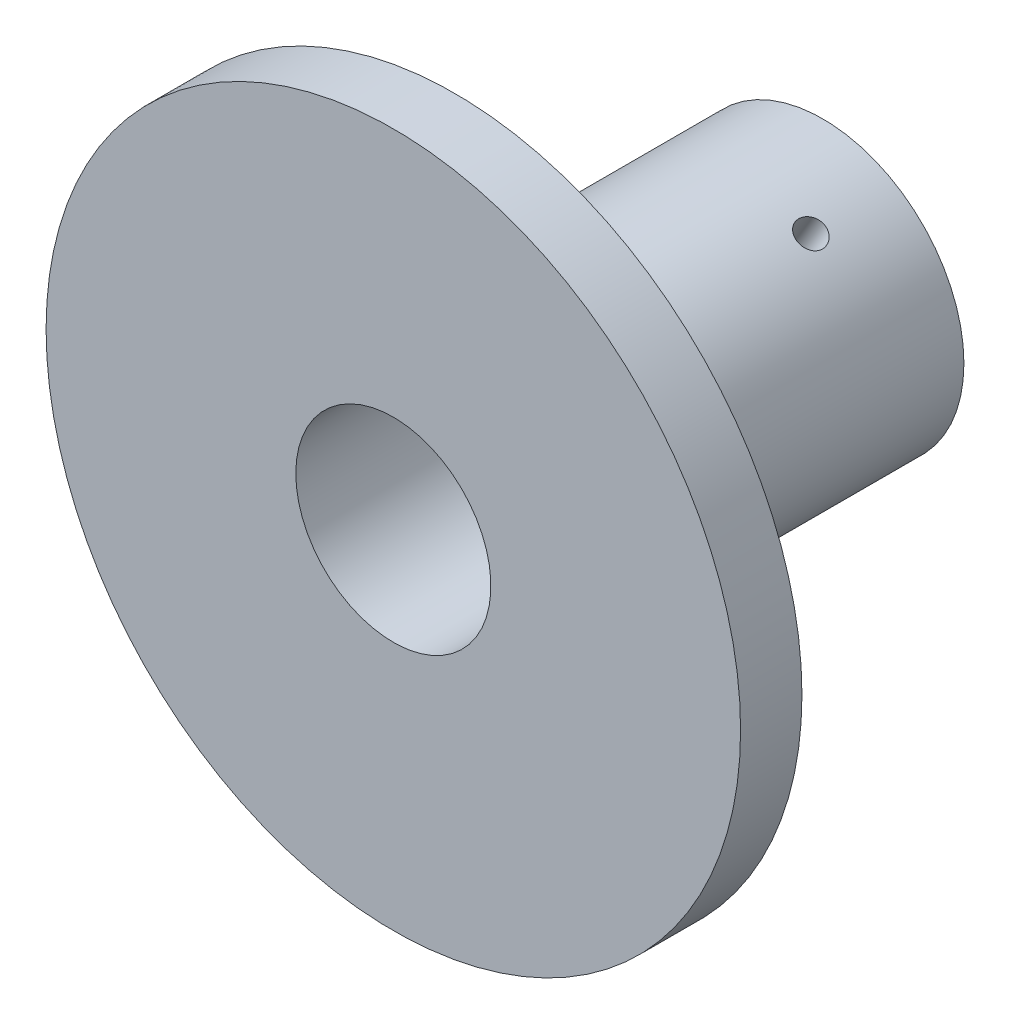
from build123d import *

# Parameters (mm, degrees)
SKETCH1_R                  = 28.3
BOSS_EXTRUDE1_DEPTH        = 5
SKETCH4_R                  = 11.5
BOSS_EXTRUDE2_DEPTH        = 30
SKETCH10_R                 = 7.95
CUT_EXTRUDE4_DEPTH         = 36
F_4_40_TAPPED_HOLE2_REACH  = 42.359
F_4_40_TAPPED_HOLE2_BORE_R = 1.1303
CIRPATTERN3_COUNT          = 3


with BuildPart() as part:
    # Sketch1 → Boss-Extrude1 (new body)
    with BuildSketch(Plane.XY):
        Circle(SKETCH1_R)
    extrude(amount=BOSS_EXTRUDE1_DEPTH)

    # Sketch4 → Boss-Extrude2 (add)
    with BuildSketch(Plane(origin=(0, 0, 0), x_dir=(-1, 0, 0), z_dir=(0, 0, -1))):
        with Locations(Location((0, 0, 0), (0, 0, 180))):  # turned: the seam where the file's is
            Circle(SKETCH4_R)
    extrude(amount=BOSS_EXTRUDE2_DEPTH)

    # Sketch10 → Cut-Extrude4 (cut, through all)
    with BuildSketch(Plane(origin=(0, 0, -30), x_dir=(-1, 0, 0), z_dir=(0, 0, -1))):
        Circle(SKETCH10_R)
    extrude(amount=-CUT_EXTRUDE4_DEPTH, mode=Mode.SUBTRACT)

    # #4-40 Tapped Hole2 bore (on position points) → #4-40 Tapped Hole2 (cut, up to next)
    with BuildSketch(Plane(origin=(-11.49770937, 0.22951958, -23.090859569), x_dir=(-0.019958224, -0.999800815, 0), z_dir=(-0.999800815, 0.019958224, 0)), mode=Mode.PRIVATE) as f_4_40_tapped_hole2_sk1:
        Circle(F_4_40_TAPPED_HOLE2_BORE_R)
    f_4_40_tapped_hole2_tool1 = extrude(f_4_40_tapped_hole2_sk1.sketch, amount=-F_4_40_TAPPED_HOLE2_REACH, mode=Mode.PRIVATE) & part.part
    f_4_40_tapped_hole2 = f_4_40_tapped_hole2_tool1.solids().sort_by_distance((-11.497709, 0.22952, -23.09086))[0]
    add(f_4_40_tapped_hole2, mode=Mode.SUBTRACT)

    # CirPattern3: #4-40 Tapped Hole2 ×3 about axis
    cirpattern3_axis = Axis((0, 0, -30), (0, 0, 1))
    for i in range(1, CIRPATTERN3_COUNT):
        add(f_4_40_tapped_hole2.rotate(cirpattern3_axis, i * 360 / CIRPATTERN3_COUNT), mode=Mode.SUBTRACT)


solid = part.part
